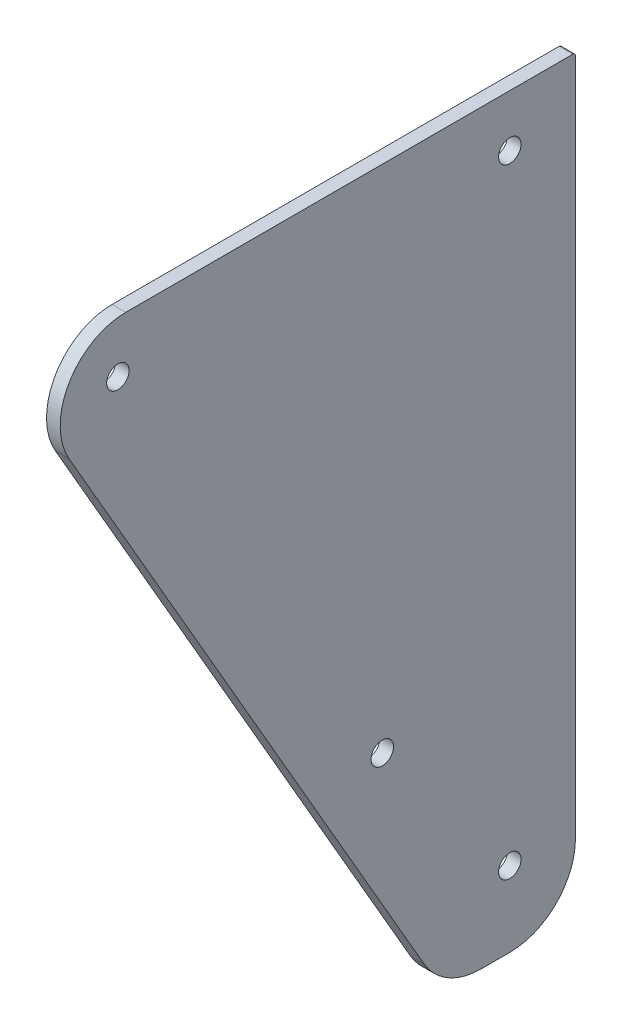
from build123d import *

# Parameters (mm, degrees)
SKETCH1_R           = 4.1
BOSS_EXTRUDE1_DEPTH = 5


with BuildPart() as part:
    # Sketch1 → Boss-Extrude1 (new body)
    with BuildSketch(Plane(origin=(0, 0, 0), x_dir=(0, -1, 0), z_dir=(-1, 0, 0))):
        with BuildLine():
            Line((-13, 31.350852961), (-238, 161.254663529))
            ThreePointArc((-238, 161.254663529), (-262, 161.254663529), (-274, 140.470053838))
            Line((-274, 140.470053838), (-274, -23))
            ThreePointArc((-274, -23), (-273.707106781, -23.707106781), (-273, -24))
            Line((-273, -24), (-25, -24))
            ThreePointArc((-25, -24), (-8.029437252, -16.970562748), (-1, 0))
            Line((-1, 0), (-1, 10.56624327))
            ThreePointArc((-1, 10.56624327), (-4.215390309, 22.56624327), (-13, 31.350852961))
        make_face()
        with Locations((-255, 143.356805184)):
            Circle(SKETCH1_R, mode=Mode.SUBTRACT)
        with Locations((-255, 0)):
            Circle(SKETCH1_R, mode=Mode.SUBTRACT)
        with Locations((-28.5, 0)):
            Circle(SKETCH1_R, mode=Mode.SUBTRACT)
        with Locations((-87.5, 46.650635095)):
            Circle(SKETCH1_R, mode=Mode.SUBTRACT)
    extrude(amount=-BOSS_EXTRUDE1_DEPTH)


solid = part.part
